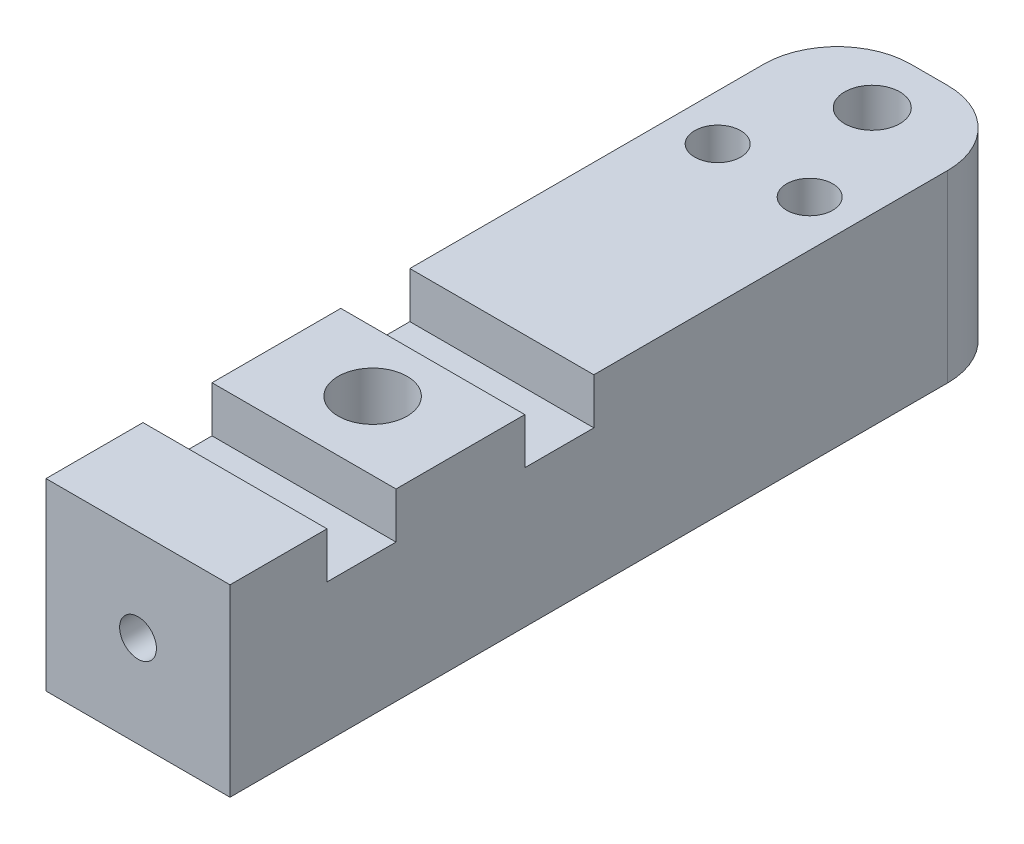
from build123d import *

# Parameters (mm, degrees)
SKETCH1_R           = 1.25
SKETCH1_R_2         = 1.875
BOSS_EXTRUDE1_DEPTH = 10
SKETCH2_W           = 10
SKETCH2_H           = 3.75
CUT_EXTRUDE1_DEPTH  = 2.5
SKETCH2_3_R         = 1.5
CUT_EXTRUDE2_DEPTH  = 6.5
SKETCH3_R           = 1
CUT_EXTRUDE3_DEPTH  = 7


with BuildPart() as part:
    # Sketch1 → Boss-Extrude1 (new body)
    with BuildSketch(Plane(origin=(0, 0, 0), x_dir=(1, 0, 0), z_dir=(0, 1, 0))):
        with BuildLine():
            Line((0, 0), (10, 0))
            Line((10, 0), (10, 39))
            ThreePointArc((10, 39), (8.828427125, 41.828427125), (6, 43))
            Line((6, 43), (4, 43))
            ThreePointArc((4, 43), (1.171572875, 41.828427125), (0, 39))
            Line((0, 39), (0, 0))
        make_face()
        with Locations((2.5, 34)):
            Circle(SKETCH1_R, mode=Mode.SUBTRACT)
        with Locations((7.5, 34)):
            Circle(SKETCH1_R, mode=Mode.SUBTRACT)
        with Locations((5, 12.75)):
            Circle(SKETCH1_R_2, mode=Mode.SUBTRACT)
    extrude(amount=BOSS_EXTRUDE1_DEPTH)

    # Sketch2 → Cut-Extrude1 (cut)
    with BuildSketch(Plane(origin=(0, 10, 0), x_dir=(1, 0, 0), z_dir=(0, 1, 0))):
        with Locations((5, 17.895308756)):
            Rectangle(SKETCH2_W, SKETCH2_H)
        with Locations((5, 7.145308756)):
            Rectangle(SKETCH2_W, SKETCH2_H)
    extrude(amount=-CUT_EXTRUDE1_DEPTH, mode=Mode.SUBTRACT)

    # Sketch2_3 → Cut-Extrude2 (cut)
    with BuildSketch(Plane(origin=(0, 10, 0), x_dir=(1, 0, 0), z_dir=(0, 1, 0))):
        with Locations((5, 39.9)):
            Circle(SKETCH2_3_R)
    extrude(amount=-CUT_EXTRUDE2_DEPTH, mode=Mode.SUBTRACT)

    # Sketch3 → Cut-Extrude3 (cut)
    with BuildSketch(Plane.XY):
        with Locations((5, 5)):
            Circle(SKETCH3_R)
    extrude(amount=-CUT_EXTRUDE3_DEPTH, mode=Mode.SUBTRACT)


solid = part.part
